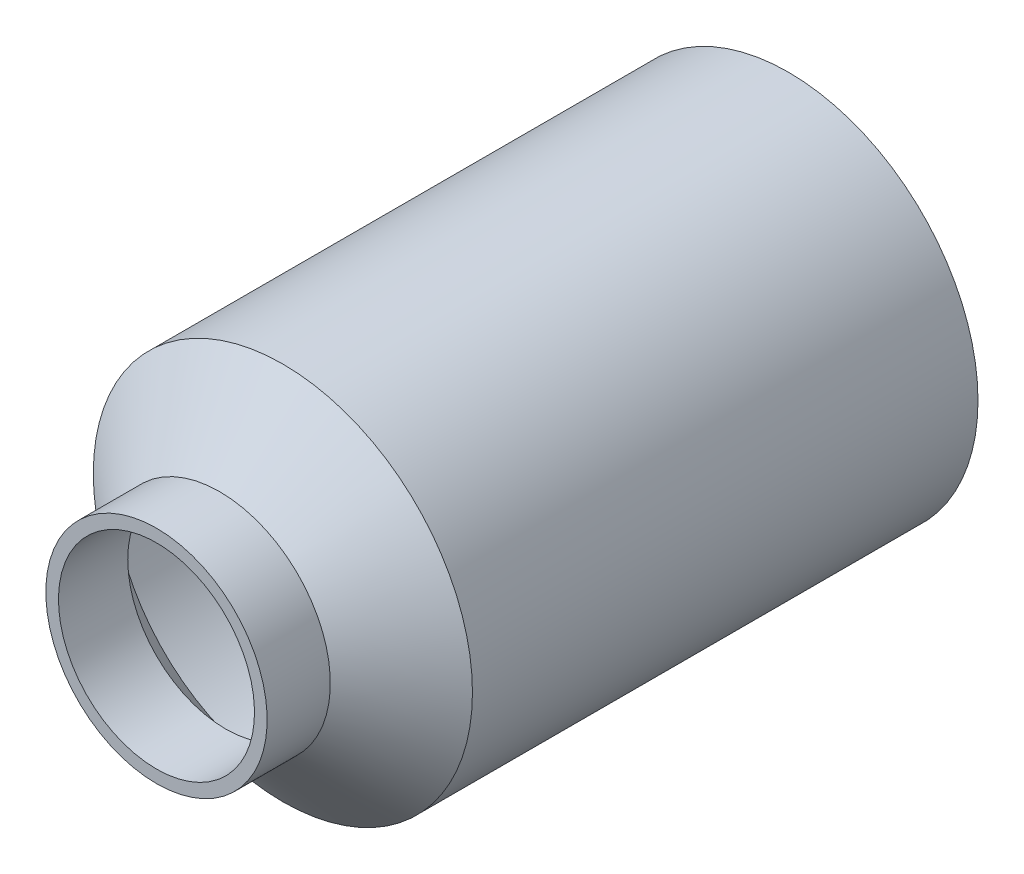
from build123d import *

# Parameters (mm, degrees)
SHELL1_T = -2.54


with BuildPart() as part:
    # Sketch1 → Revolve1 (revolve)
    with BuildSketch(Plane.YZ):
        Polygon((0, 0), (0, 101.6), (15.862294916, 114.3), (15.862294916, 127), (38.1, 127), (38.1, 0), align=None)
    revolve(axis=Axis((0, 38.1, 127), (0, 0, -1)))

    # Shell1
    shell1_openings = [part.faces().sort_by_distance(p)[0] for p in [
        (0, 38.1, 127),
    ]]
    offset(amount=SHELL1_T, openings=shell1_openings, kind=Kind.INTERSECTION)


solid = part.part
